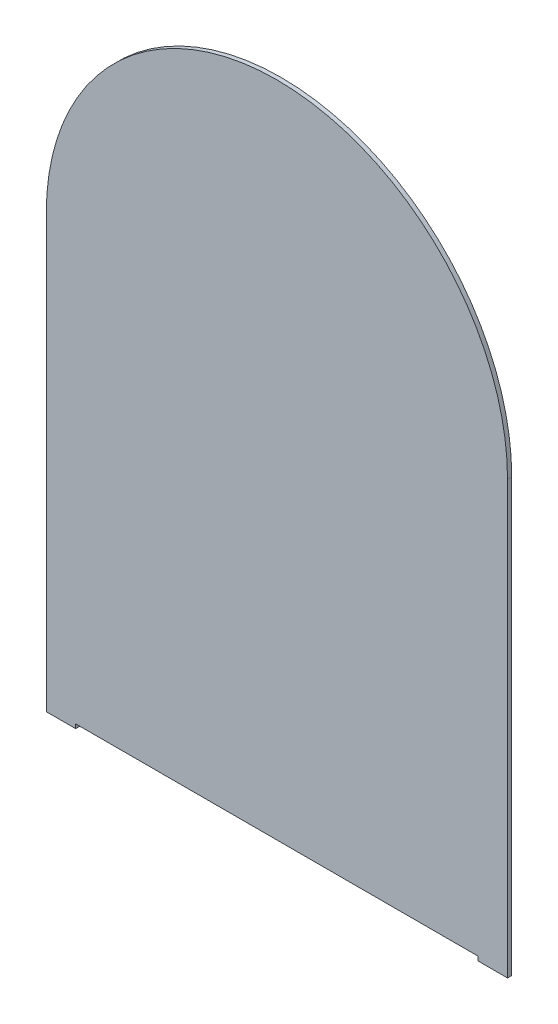
from build123d import *

# Parameters (mm, degrees)
BOSS_EXTRUDE1_DEPTH = 3.175
SKETCH2_W           = 304.8
SKETCH2_H           = 3.175
CUT_EXTRUDE1_DEPTH  = 3.175


with BuildPart() as part:
    # Sketch1 → Boss-Extrude1 (new body)
    with BuildSketch(Plane.XY):
        with BuildLine():
            Line((0, 0), (0, -327.025))
            Line((0, -327.025), (349.25, -327.025))
            Line((349.25, -327.025), (349.25, 0))
            ThreePointArc((349.25, 0), (174.625, 174.625), (0, 0))
        make_face()
    extrude(amount=BOSS_EXTRUDE1_DEPTH)

    # Sketch2 → Cut-Extrude1 (cut)
    with BuildSketch(Plane.XY.offset(3.175)):
        with Locations((174.625, -325.4375)):
            Rectangle(SKETCH2_W, SKETCH2_H)
    extrude(amount=-CUT_EXTRUDE1_DEPTH, mode=Mode.SUBTRACT)


solid = part.part
